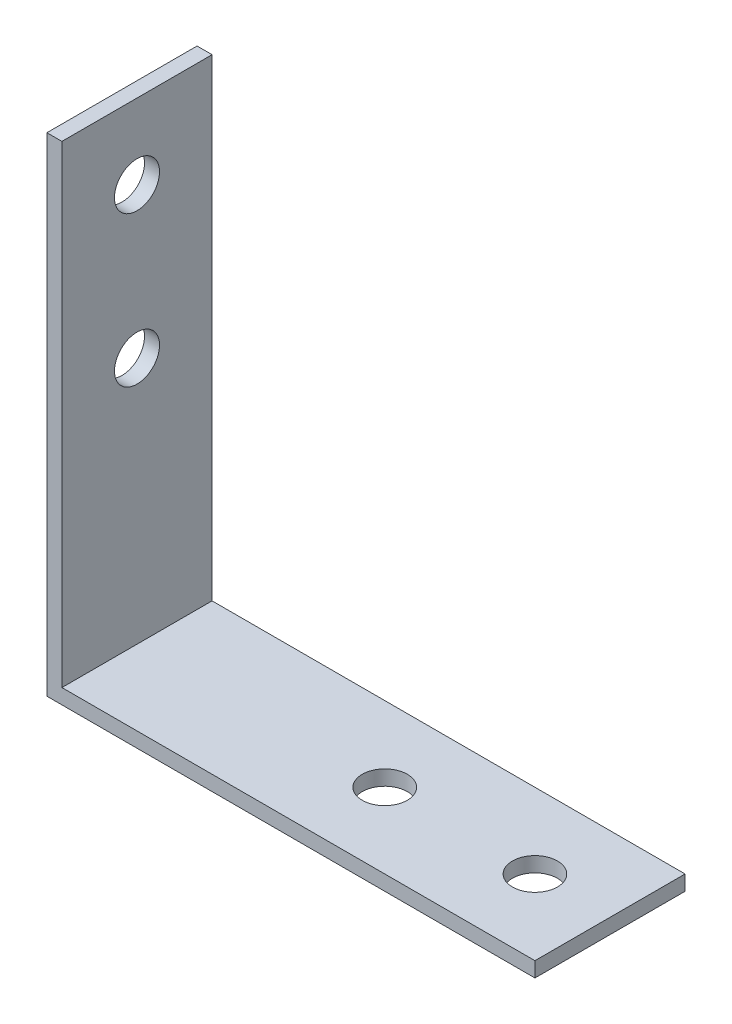
from build123d import *

# Parameters (mm, degrees)
BOSS_EXTRU_1_DEPTH         = 10
ESQUISSE2_R                = 1.5
ENL_V_MAT_EXTRU_1_DEPTH    = 33.5
R_P_TITION_LIN_AIRE1_COUNT = 2
R_P_TITION_LIN_AIRE1_PITCH = 10
ESQUISSE3_R                = 1.5
ENL_V_MAT_EXTRU_2_DEPTH    = 33.5
R_P_TITION_LIN_AIRE2_COUNT = 2
R_P_TITION_LIN_AIRE2_PITCH = 10


with BuildPart() as part:
    # Esquisse1 → Boss.-Extru.1 (new body)
    with BuildSketch(Plane.XY):
        Polygon((0, 0), (32.5, 0), (32.5, 1), (1, 1), (1, 32.5), (0, 32.5), align=None)
    extrude(amount=BOSS_EXTRU_1_DEPTH)

    # Esquisse2 → Enlèv. mat.-Extru.1 (cut, through all)
    with BuildSketch(Plane.ZY):
        with Locations((5, 27.5)):
            Circle(ESQUISSE2_R)
    enl_v_mat_extru_1 = extrude(amount=-ENL_V_MAT_EXTRU_1_DEPTH, mode=Mode.SUBTRACT)

    # Répétition linéaire1: Enlèv. mat.-Extru.1 ×2
    with Locations(*[(0, -i * R_P_TITION_LIN_AIRE1_PITCH, 0) for i in range(1, R_P_TITION_LIN_AIRE1_COUNT)]):
        add(enl_v_mat_extru_1, mode=Mode.SUBTRACT)

    # Esquisse3 → Enlèv. mat.-Extru.2 (cut, through all)
    with BuildSketch(Plane.XZ):
        with Locations((27.5, 5)):
            Circle(ESQUISSE3_R)
    enl_v_mat_extru_2 = extrude(amount=-ENL_V_MAT_EXTRU_2_DEPTH, mode=Mode.SUBTRACT)

    # Répétition linéaire2: Enlèv. mat.-Extru.2 ×2
    with Locations(*[(-i * R_P_TITION_LIN_AIRE2_PITCH, 0, 0) for i in range(1, R_P_TITION_LIN_AIRE2_COUNT)]):
        add(enl_v_mat_extru_2, mode=Mode.SUBTRACT)


solid = part.part
